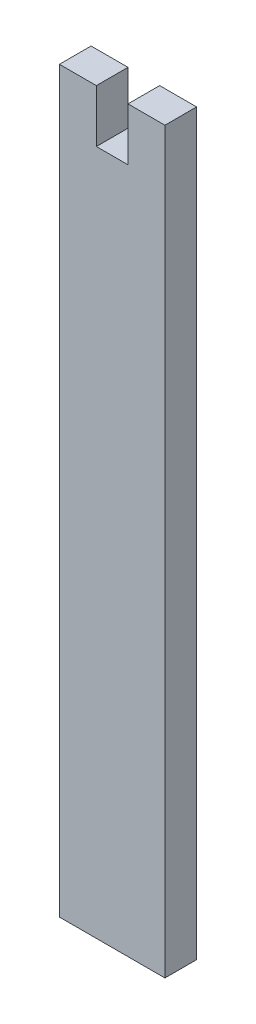
from build123d import *

# Parameters (mm, degrees)
BOSS_EXTRUDE1_DEPTH = 1.5


with BuildPart() as part:
    # Sketch1 → Boss-Extrude1 (new body, symmetric)
    with BuildSketch(Plane.XY):
        Polygon((-1.5, 35), (-5, 35), (-5, -35), (5, -35), (5, 35), (1.5, 35), (1.5, 30), (-1.5, 30), align=None)
    extrude(amount=BOSS_EXTRUDE1_DEPTH, both=True)


solid = part.part
